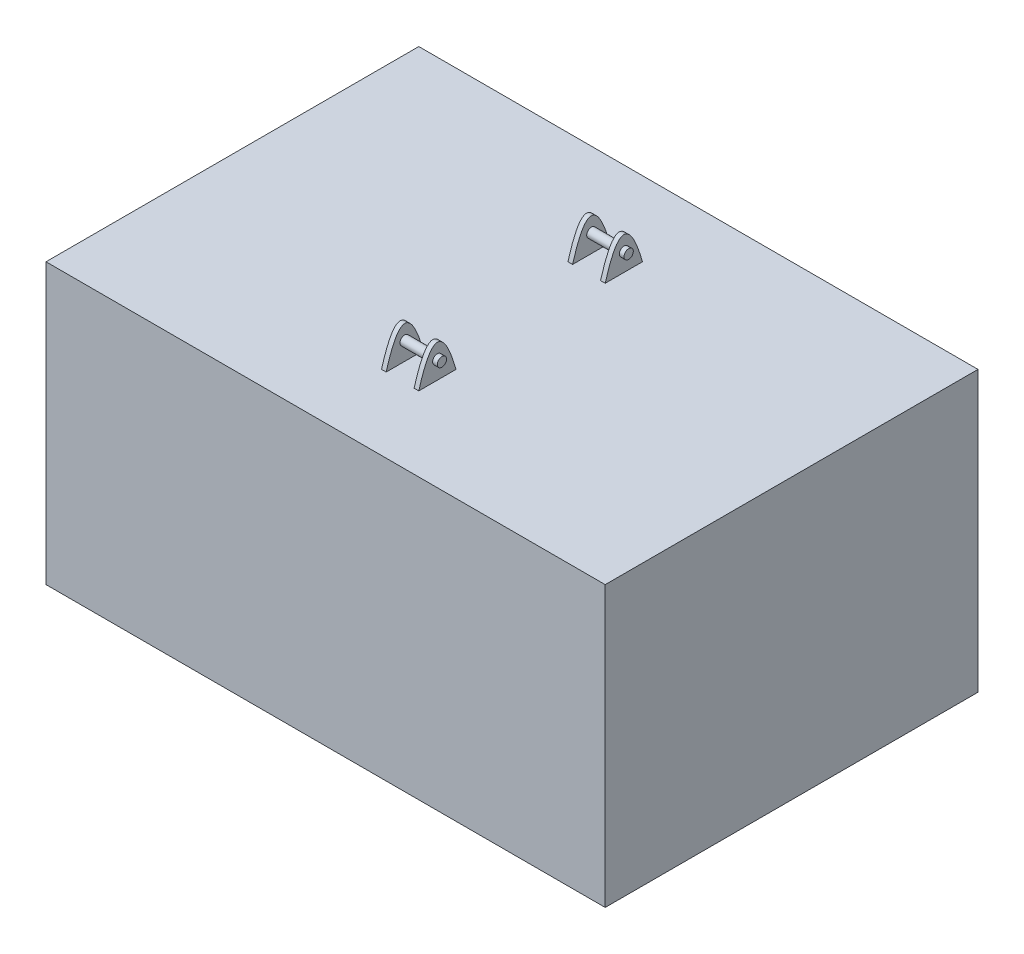
from build123d import *

# Parameters (mm, degrees)
BOSS_EXTRUDE1_DEPTH      = 300
BOSS_EXTRUDE1_DEPTH_BACK = 300
SKETCH2_W                = 400
SKETCH2_H                = 300
BOSS_EXTRUDE4_DEPTH      = 5
BOSS_EXTRUDE5_START      = -20
SKETCH10_R               = 5
BOSS_EXTRUDE5_DEPTH      = 25
MIRROR2_COPY_1_DEPTH     = 5
MIRROR2_START            = -20
MIRROR2_COPY_2_SKETCH_R  = 5
MIRROR2_COPY_2_DEPTH     = 25


with BuildPart() as part:
    # Sketch2 → Boss-Extrude1 (new, two sides: drawn at the far end of the back side and taken through both)
    with BuildSketch(Plane(origin=(0, 0, 0), x_dir=(0, 0, -1), z_dir=(1, 0, 0)).offset(-BOSS_EXTRUDE1_DEPTH_BACK)):
        Rectangle(SKETCH2_W, SKETCH2_H)
    extrude(amount=BOSS_EXTRUDE1_DEPTH + BOSS_EXTRUDE1_DEPTH_BACK)

    # Sketch9 → Boss-Extrude4 (add)
    with BuildSketch(Plane(origin=(20, 0, 0), x_dir=(0, 0, -1), z_dir=(1, 0, 0))):
        with BuildLine():
            Line((-80, 150), (-100, 150))
            Line((-100, 150), (-120, 150))
            add(Edge.make_bspline(
                [(-120, 150), (-100, 220.369583086), (-80, 150)],
                knots=[0, 0, 0, 1, 1, 1], degree=2))
        make_face()
    boss_extrude4 = extrude(amount=-BOSS_EXTRUDE4_DEPTH)

    # Sketch10 → Boss-Extrude5 (add)
    with BuildSketch(Plane(origin=(20, 0, 0), x_dir=(0, 0, -1), z_dir=(1, 0, 0)).offset(BOSS_EXTRUDE5_START)):
        with Locations((-100.167931578, 169.588362033)):
            Circle(SKETCH10_R)
    boss_extrude5 = extrude(amount=BOSS_EXTRUDE5_DEPTH)

    # Mirror1: Boss-Extrude4, Boss-Extrude5 across plane
    add(boss_extrude4.mirror(Plane(origin=(0, 0, 0), x_dir=(0, 0, 1), z_dir=(1, 0, 0))))
    add(boss_extrude5.mirror(Plane(origin=(0, 0, 0), x_dir=(0, 0, 1), z_dir=(1, 0, 0))))

    # Mirror2: Boss-Extrude4, Boss-Extrude5 across plane
    add(boss_extrude4.mirror(Plane.XY))
    add(boss_extrude5.mirror(Plane.XY))

    # Mirror2 copy 1 sketch → Mirror2 copy 1 (add)
    with BuildSketch(Plane.ZY.offset(20)):
        with BuildLine():
            Line((-80, 150), (-100, 150))
            Line((-100, 150), (-120, 150))
            add(Edge.make_bspline(
                [(-120, 150), (-100, 220.369583086), (-80, 150)],
                knots=[0, 0, 0, 1, 1, 1], degree=2))
        make_face()
    extrude(amount=-MIRROR2_COPY_1_DEPTH)

    # Mirror2 copy 2 sketch → Mirror2 copy 2 (add)
    with BuildSketch(Plane.ZY.offset(20).offset(MIRROR2_START)):
        with Locations((-100.167931578, 169.588362033)):
            Circle(MIRROR2_COPY_2_SKETCH_R)
    extrude(amount=MIRROR2_COPY_2_DEPTH)


solid = part.part
